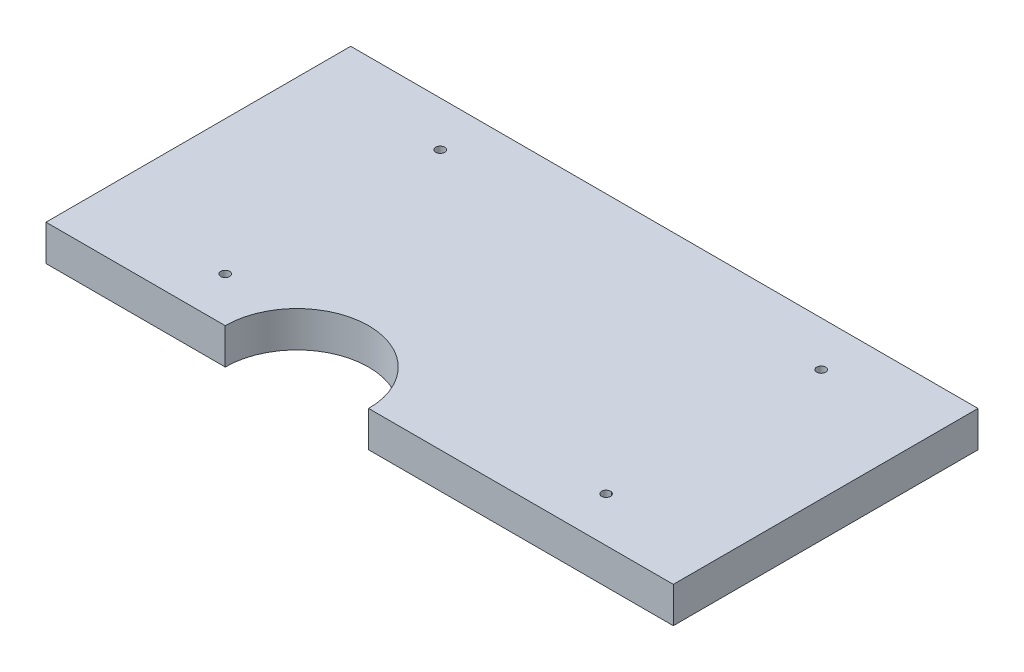
from build123d import *

# Parameters (mm, degrees)
SKETCH1_R           = 1
BOSS_EXTRUDE1_DEPTH = 8


with BuildPart() as part:
    # Sketch1 → Boss-Extrude1 (new body)
    with BuildSketch(Plane(origin=(0, 0, 0), x_dir=(1, 0, 0), z_dir=(0, 1, 0))):
        with BuildLine():
            Line((-62.675339064, 42.746325997), (77.324660936, 42.746325997))
            Line((77.324660936, 42.746325997), (77.324660936, -25.253674003))
            Line((77.324660936, -25.253674003), (9.324660936, -25.253674003))
            ThreePointArc((9.324660936, -25.253674003), (-6.675339064, -9.253674003), (-22.675339064, -25.253674003))
            Line((-22.675339064, -25.253674003), (-62.675339064, -25.253674003))
            Line((-62.675339064, -25.253674003), (-62.675339064, 42.746325997))
        make_face()
        with Locations((-32.675339064, 32.746325997)):
            Circle(SKETCH1_R, mode=Mode.SUBTRACT)
        with Locations((-32.675339064, -15.253674003)):
            Circle(SKETCH1_R, mode=Mode.SUBTRACT)
        with Locations((52.324660936, 32.746325997)):
            Circle(SKETCH1_R, mode=Mode.SUBTRACT)
        with Locations((52.324660936, -15.253674003)):
            Circle(SKETCH1_R, mode=Mode.SUBTRACT)
    extrude(amount=BOSS_EXTRUDE1_DEPTH)


solid = part.part
